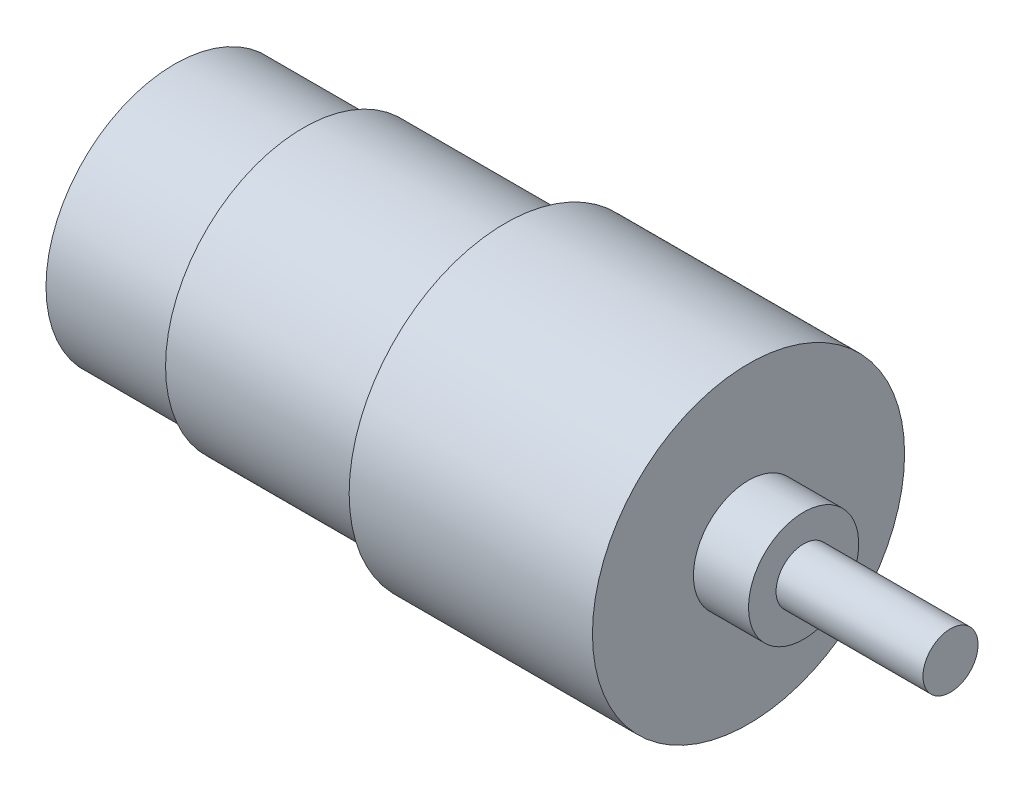
from build123d import *


with BuildPart() as part:
    # Sketch1 → Revolve1 (revolve)
    with BuildSketch(Plane(origin=(0, 0, 0), x_dir=(1, 0, 0), z_dir=(0, 1, 0))):
        Polygon((0, 0), (0, 14), (14.02184466, 14), (14.02184466, 15), (36.019417476, 15), (36.019417476, 17), (62.519417476, 17), (62.519417476, 6), (68.519417476, 6), (68.519417476, 3), (84.519417476, 3), (84.519417476, 0), align=None)
    revolve(axis=Axis((-18.652912621, 0, 0), (1, 0, 0)))


solid = part.part
